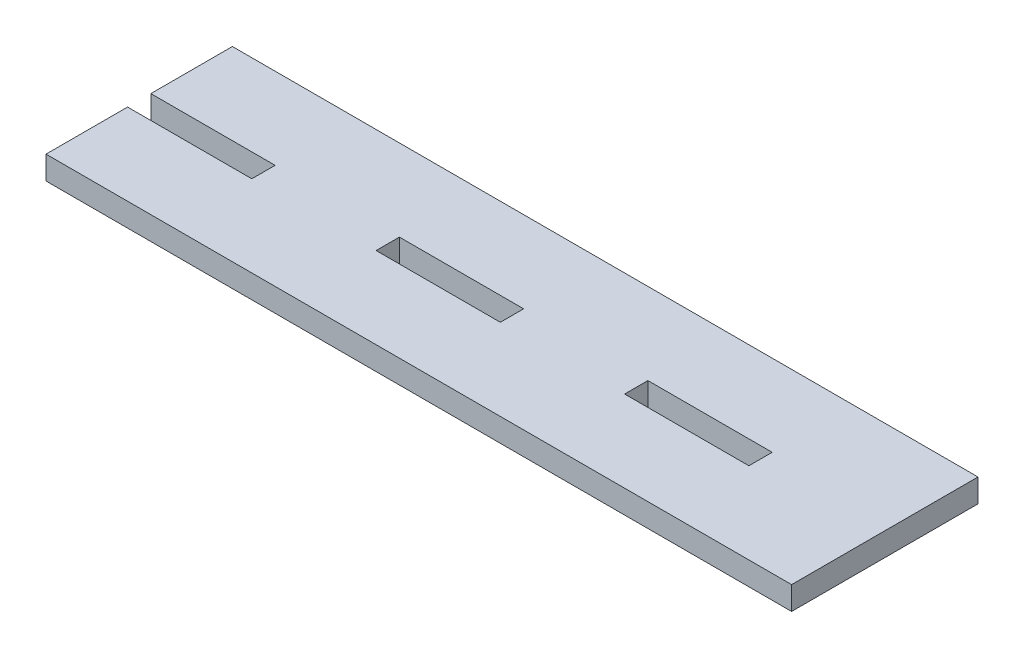
from build123d import *

# Parameters (mm, degrees)
SKETCH1_W           = 25.4
SKETCH1_H           = 4.7625
BOSS_EXTRUDE1_DEPTH = 4.7625


with BuildPart() as part:
    # Sketch1 → Boss-Extrude1 (new body)
    with BuildSketch(Plane(origin=(0, 0, 0), x_dir=(1, 0, 0), z_dir=(0, 1, 0))):
        Polygon((-76.2, 19.05), (-76.2, 2.38125), (-50.8, 2.38125), (-50.8, -2.38125), (-76.2, -2.38125), (-76.2, -19.05), (76.2, -19.05), (76.2, 19.05), align=None)
        with Locations((-12.7, 0)):
            Rectangle(SKETCH1_W, SKETCH1_H, mode=Mode.SUBTRACT)
        with Locations((38.1, 0)):
            Rectangle(SKETCH1_W, SKETCH1_H, mode=Mode.SUBTRACT)
    extrude(amount=BOSS_EXTRUDE1_DEPTH)


solid = part.part
